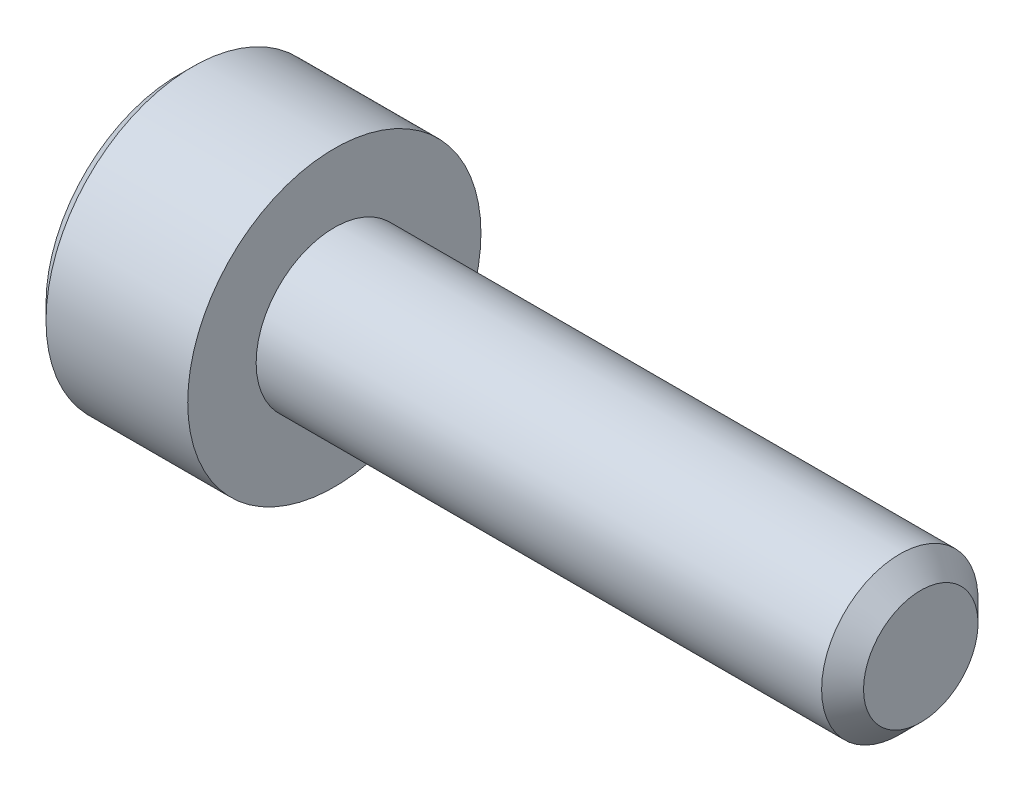
from build123d import *

# Parameters (mm, degrees)
CUT_EXTRUDE1_DEPTH = 0.64


with BuildPart() as part:
    # Sketch1 → Revolve1 (revolve)
    with BuildSketch(Plane.XY):
        Polygon((-1.6, 0), (-1.6, 1.35), (-1.45, 1.5), (0, 1.5), (0, 0.8), (5.7855, 0.8), (6, 0.5855), (6, 0), align=None)
    revolve(axis=Axis((6, 0, 0), (-1, 0, 0)))

    # Sketch2 → Cut-Extrude1 (cut)
    with BuildSketch(Plane(origin=(-1.6, 0, 0), x_dir=(0, 0, -1), z_dir=(1, 0, 0))):
        Polygon((-0.75, -0.433012702), (0, -0.866025404), (0.75, -0.433012702), (0.75, 0.433012702), (0, 0.866025404), (-0.75, 0.433012702), align=None)
    extrude(amount=CUT_EXTRUDE1_DEPTH, mode=Mode.SUBTRACT)


solid = part.part
